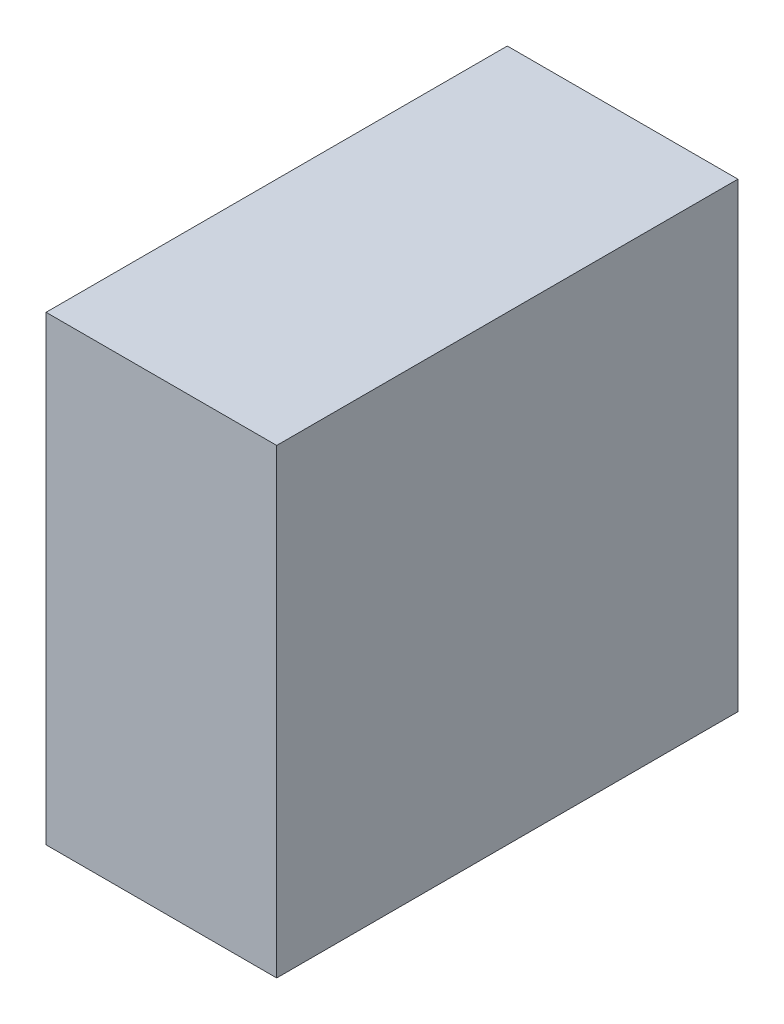
from build123d import *

# Parameters (mm, degrees)
SKETCH1_W           = 30
SKETCH1_H           = 60
BOSS_EXTRUDE1_DEPTH = 60


with BuildPart() as part:
    # Sketch1 → Boss-Extrude1 (new body)
    with BuildSketch(Plane(origin=(0, 0, 0), x_dir=(1, 0, 0), z_dir=(0, 1, 0))):
        Rectangle(SKETCH1_W, SKETCH1_H)
    extrude(amount=BOSS_EXTRUDE1_DEPTH)


solid = part.part
